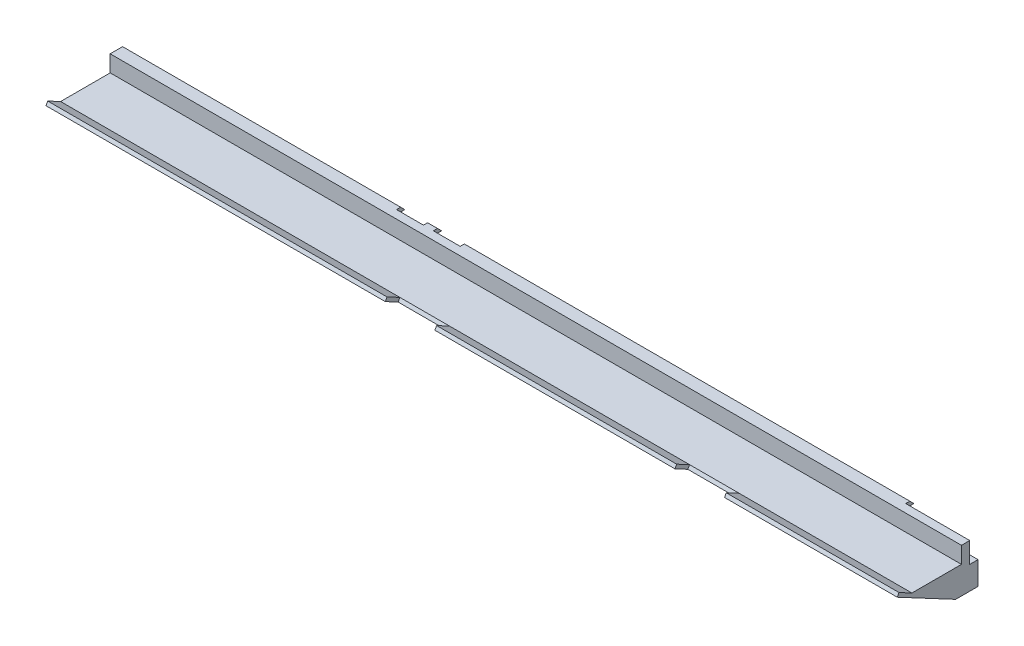
from build123d import *

# Parameters (mm, degrees)
EXTRUDE_PROFILE_DEPTH = 206
SKETCH6_W             = 185
SKETCH6_H             = 5.633658753
AIR_SPACE_DEPTH       = 45
SKETCH7_W             = 12
SKETCH7_H             = 3.530528437
TAB_CUTS_DEPTH        = 8.515248173
SKETCH8_W             = 15.5
SKETCH8_H             = 10
SKETCH8_W_2           = 6.5
CUT_EXTRUDE1_DEPTH    = 2


with BuildPart() as part:
    # Sketch1 → Extrude profile (new body)
    with BuildSketch(Plane(origin=(0, 0, 0), x_dir=(0, 0, -1), z_dir=(1, 0, 0))):
        Polygon((0, 1), (12, 1), (12, 4), (12, 5), (15, 5), (16, 4), (14, 4), (14, 2), (16, 2), (16, -5.633658753), (10.595371114, -5.633658753), (0, 0), (-3.531790371, 1.877886251), (-3.117271585, 2.657482703), align=None)
    extrude(amount=EXTRUDE_PROFILE_DEPTH)

    # Sketch6 → Air space (cut)
    with BuildSketch(Plane(origin=(0, 0, -16), x_dir=(-1, 0, 0), z_dir=(0, 0, -1))):
        with Locations((-107.5, -2.816829377)):
            Rectangle(SKETCH6_W, SKETCH6_H)
    extrude(amount=-AIR_SPACE_DEPTH, mode=Mode.SUBTRACT)

    # Sketch7 → Tab cuts (cut, through all)
    with BuildSketch(Plane(origin=(0, 0.779596452, -0.414518786), x_dir=(1, 0, 0), z_dir=(0, 0.882947593, -0.469471563))):
        with Locations((158.2, -2.234735781)):
            Rectangle(SKETCH7_W, SKETCH7_H)
        with Locations((88.1, -2.234735781)):
            Rectangle(SKETCH7_W, SKETCH7_H)
    extrude(amount=-TAB_CUTS_DEPTH, mode=Mode.SUBTRACT)

    # Sketch8 → Cut-Extrude1 (cut)
    with BuildSketch(Plane(origin=(0, 0, -16), x_dir=(-1, 0, 0), z_dir=(0, 0, -1))):
        with Locations((-198.25, 5)):
            Rectangle(SKETCH8_W, SKETCH8_H)
        with Locations((-70.55, 5)):
            Rectangle(SKETCH8_W_2, SKETCH8_H)
        with Locations((-79.45, 5)):
            Rectangle(SKETCH8_W_2, SKETCH8_H)
    extrude(amount=-CUT_EXTRUDE1_DEPTH, mode=Mode.SUBTRACT)


solid = part.part
